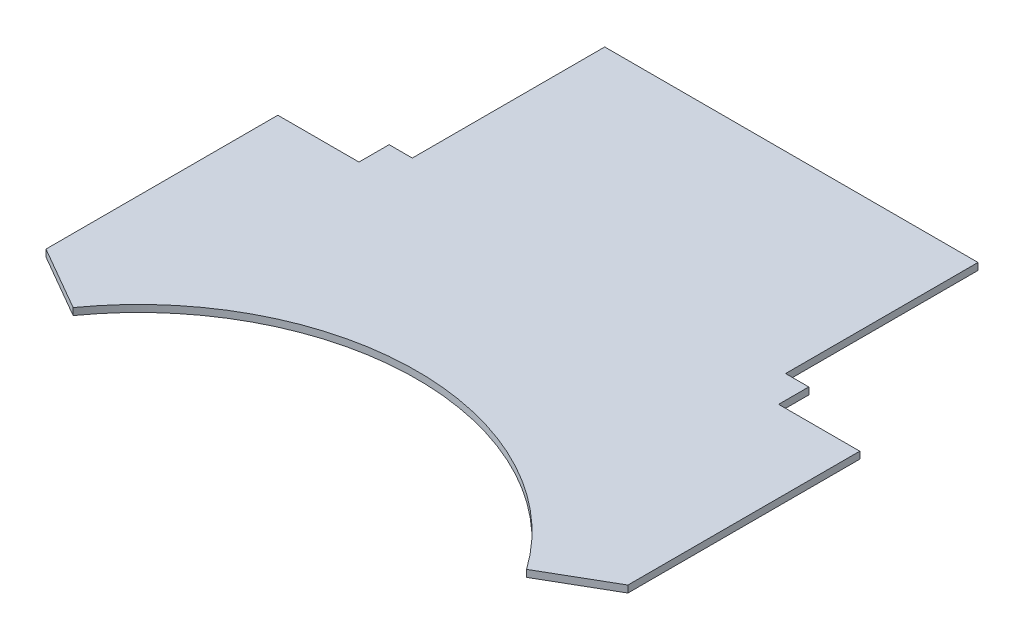
from build123d import *

# Parameters (mm, degrees)
EXTRUSION1_DEPTH = 3


with BuildPart() as part:
    # Esquisse1 → Extrusion1 (new body)
    with BuildSketch(Plane(origin=(0, 0, 0), x_dir=(1, 0, 0), z_dir=(0, 1, 0))):
        with BuildLine():
            Line((80.5, 0), (-80.5, 0))
            Line((-80.5, 0), (-80.5, -83))
            Line((-80.5, -83), (-90.5, -83))
            Line((-90.5, -83), (-90.5, -96))
            Line((-90.5, -96), (-125.5, -96))
            Line((-125.5, -96), (-125.5, -196))
            Line((-125.5, -196), (-97.787187079, -212))
            ThreePointArc((-97.787187079, -212), (0, -161.553332366), (97.787187079, -212))
            Line((97.787187079, -212), (125.5, -196))
            Line((125.5, -196), (125.5, -96))
            Line((125.5, -96), (90.5, -96))
            Line((90.5, -96), (90.5, -83))
            Line((90.5, -83), (80.5, -83))
            Line((80.5, -83), (80.5, 0))
        make_face()
    extrude(amount=EXTRUSION1_DEPTH)


solid = part.part
